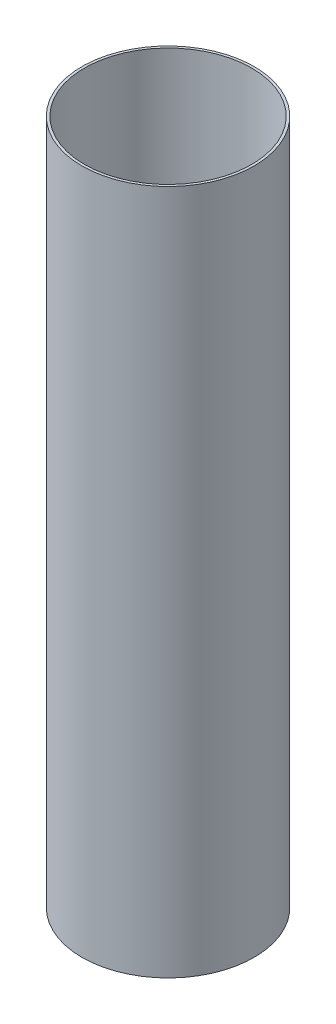
from build123d import *

# Parameters (mm, degrees)
SKETCH1_R           = 65.405
SKETCH1_R_2         = 63.5
BOSS_EXTRUDE1_DEPTH = 260.35


with BuildPart() as part:
    # Sketch1 → Boss-Extrude1 (new body, symmetric)
    with BuildSketch(Plane(origin=(0, 0, 0), x_dir=(1, 0, 0), z_dir=(0, 1, 0))):
        Circle(SKETCH1_R)
        Circle(SKETCH1_R_2, mode=Mode.SUBTRACT)
    extrude(amount=BOSS_EXTRUDE1_DEPTH, both=True)


solid = part.part
